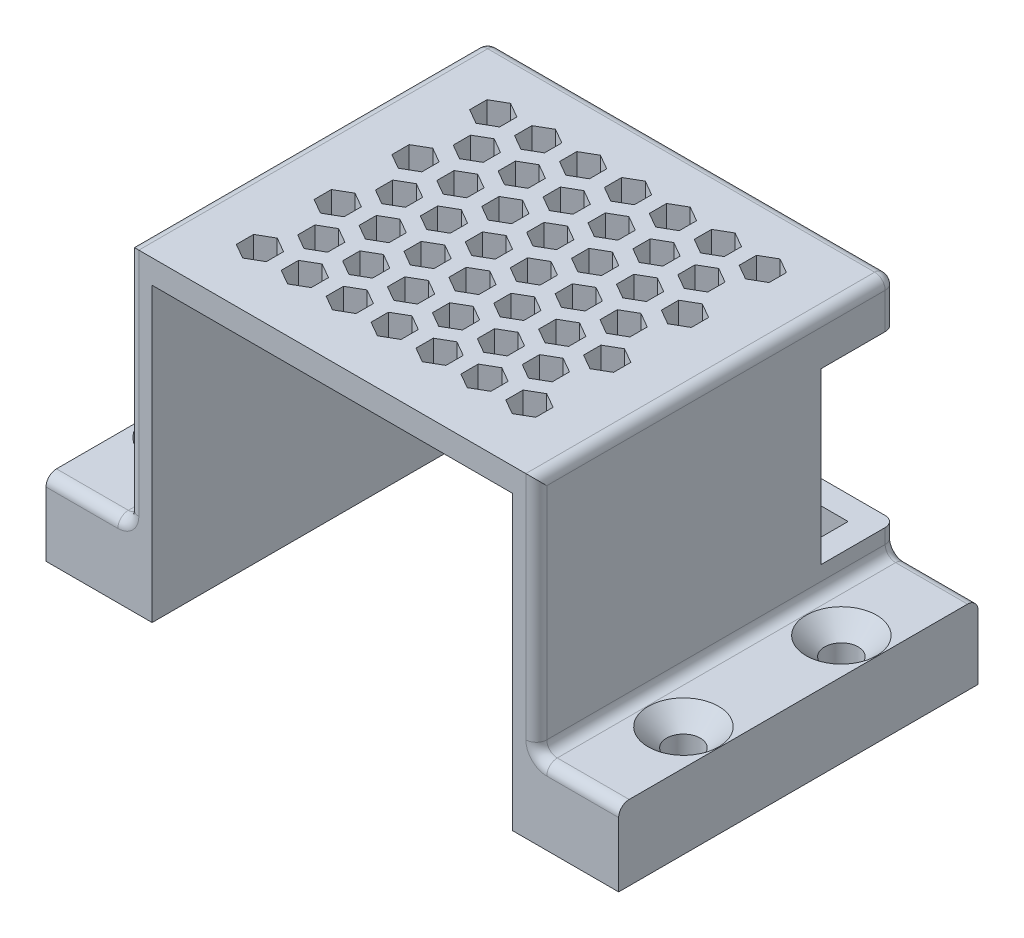
from build123d import *

# Parameters (mm, degrees)
SKETCH1_W                                       = 54.5
SKETCH1_H                                       = 48
BOSS_EXTRUDE1_DEPTH                             = 42.2
SHELL1_T                                        = -3.175
SKETCH2_W                                       = 48
SKETCH2_H                                       = 10
BOSS_EXTRUDE2_DEPTH                             = 11
FILLET1_R                                       = 1.4
FILLET2_R                                       = 1.4
CUT_EXTRUDE1_DEPTH                              = 12
FILLET3_R                                       = 1.4
CSK_FOR_M4_FLAT_HEAD_MACHINE_SCREW1_D           = 4.5
CSK_FOR_M4_FLAT_HEAD_MACHINE_SCREW1_DEPTH       = 10
CSK_FOR_M4_FLAT_HEAD_MACHINE_SCREW1_CSINK_D     = 9.4
CSK_FOR_M4_FLAT_HEAD_MACHINE_SCREW1_CSINK_ANGLE = 90
SKETCH8_W                                       = 21.374873602
SKETCH8_H                                       = 22.656356573
CUT_EXTRUDE2_DEPTH                              = 10


with BuildPart() as part:
    # Sketch1 → Boss-Extrude1 (new body)
    with BuildSketch(Plane(origin=(0, 0, 0), x_dir=(1, 0, 0), z_dir=(0, 1, 0))):
        Rectangle(SKETCH1_W, SKETCH1_H)
    extrude(amount=BOSS_EXTRUDE1_DEPTH)

    # Shell1
    shell1_openings = [part.faces().sort_by_distance(p)[0] for p in [
        (0, 0, 0),
        (0, 21.1, 24),
    ]]
    offset(amount=SHELL1_T, openings=shell1_openings, kind=Kind.INTERSECTION)

    # Sketch2 → Boss-Extrude2 (add)
    with BuildSketch(Plane(origin=(27.25, 0, 0), x_dir=(0, 0, -1), z_dir=(1, 0, 0))):
        with Locations((0, 5)):
            Rectangle(SKETCH2_W, SKETCH2_H)
    boss_extrude2 = extrude(amount=BOSS_EXTRUDE2_DEPTH)

    # Fillet1
    fillet1_edges = [part.edges().sort_by_distance(p)[0] for p in [
        (27.25, 10, 0),
    ]]
    fillet(fillet1_edges, radius=FILLET1_R)

    # Mirror1: Boss-Extrude2 across plane
    add(boss_extrude2.mirror(Plane(origin=(0, 0, 0), x_dir=(0, 0, 1), z_dir=(1, 0, 0))))

    # Fillet2
    fillet2_edges = [part.edges().sort_by_distance(p)[0] for p in [
        (-27.25, 10, 0),
    ]]
    fillet(fillet2_edges, radius=FILLET2_R)

    # Sketch3 → Cut-Extrude1 (cut)
    with BuildSketch(Plane(origin=(0, 42.2, 0), x_dir=(1, 0, 0), z_dir=(0, 1, 0))):
        Polygon((-7, 9.149745962), (-7, 11.459147039), (-9, 12.613847577), (-11, 11.459147039), (-11, 9.149745962), (-9, 7.995045424), align=None)
        Polygon((-13, 9.149745962), (-13, 11.459147039), (-15, 12.613847577), (-17, 11.459147039), (-17, 9.149745962), (-15, 7.995045424), align=None)
        Polygon((-16, 14.345898385), (-16, 16.655299462), (-18, 17.81), (-20, 16.655299462), (-20, 14.345898385), (-18, 13.191197846), align=None)
        Polygon((-10, 14.345898385), (-10, 16.655299462), (-12, 17.81), (-14, 16.655299462), (-14, 14.345898385), (-12, 13.191197846), align=None)
        Polygon((-1, 9.149745962), (-1, 11.459147039), (-3, 12.613847577), (-5, 11.459147039), (-5, 9.149745962), (-3, 7.995045424), align=None)
        Polygon((-4, 14.345898385), (-4, 16.655299462), (-6, 17.81), (-8, 16.655299462), (-8, 14.345898385), (-6, 13.191197846), align=None)
        Polygon((5, 9.149745962), (5, 11.459147039), (3, 12.613847577), (1, 11.459147039), (1, 9.149745962), (3, 7.995045424), align=None)
        Polygon((2, 14.345898385), (2, 16.655299462), (0, 17.81), (-2, 16.655299462), (-2, 14.345898385), (0, 13.191197846), align=None)
        Polygon((11, 9.149745962), (11, 11.459147039), (9, 12.613847577), (7, 11.459147039), (7, 9.149745962), (9, 7.995045424), align=None)
        Polygon((8, 14.345898385), (8, 16.655299462), (6, 17.81), (4, 16.655299462), (4, 14.345898385), (6, 13.191197846), align=None)
        Polygon((17, 9.149745962), (17, 11.459147039), (15, 12.613847577), (13, 11.459147039), (13, 9.149745962), (15, 7.995045424), align=None)
        Polygon((14, 14.345898385), (14, 16.655299462), (12, 17.81), (10, 16.655299462), (10, 14.345898385), (12, 13.191197846), align=None)
        Polygon((20, 14.345898385), (20, 16.655299462), (18, 17.81), (16, 16.655299462), (16, 14.345898385), (18, 13.191197846), align=None)
        Polygon((-7, -1.240254038), (-7, 1.069147039), (-9, 2.223847577), (-11, 1.069147039), (-11, -1.240254038), (-9, -2.394954576), align=None)
        Polygon((-10, 3.955898385), (-10, 6.265299462), (-12, 7.42), (-14, 6.265299462), (-14, 3.955898385), (-12, 2.801197846), align=None)
        Polygon((-1, -1.240254038), (-1, 1.069147039), (-3, 2.223847577), (-5, 1.069147039), (-5, -1.240254038), (-3, -2.394954576), align=None)
        Polygon((-4, 3.955898385), (-4, 6.265299462), (-6, 7.42), (-8, 6.265299462), (-8, 3.955898385), (-6, 2.801197846), align=None)
        Polygon((5, -1.240254038), (5, 1.069147039), (3, 2.223847577), (1, 1.069147039), (1, -1.240254038), (3, -2.394954576), align=None)
        Polygon((2, 3.955898385), (2, 6.265299462), (0, 7.42), (-2, 6.265299462), (-2, 3.955898385), (0, 2.801197846), align=None)
        Polygon((11, -1.240254038), (11, 1.069147039), (9, 2.223847577), (7, 1.069147039), (7, -1.240254038), (9, -2.394954576), align=None)
        Polygon((8, 3.955898385), (8, 6.265299462), (6, 7.42), (4, 6.265299462), (4, 3.955898385), (6, 2.801197846), align=None)
        Polygon((17, -1.240254038), (17, 1.069147039), (15, 2.223847577), (13, 1.069147039), (13, -1.240254038), (15, -2.394954576), align=None)
        Polygon((14, 3.955898385), (14, 6.265299462), (12, 7.42), (10, 6.265299462), (10, 3.955898385), (12, 2.801197846), align=None)
        Polygon((20, 3.955898385), (20, 6.265299462), (18, 7.42), (16, 6.265299462), (16, 3.955898385), (18, 2.801197846), align=None)
        Polygon((-7, -11.630254038), (-7, -9.320852961), (-9, -8.166152423), (-11, -9.320852961), (-11, -11.630254038), (-9, -12.784954576), align=None)
        Polygon((-10, -6.434101615), (-10, -4.124700538), (-12, -2.97), (-14, -4.124700538), (-14, -6.434101615), (-12, -7.588802154), align=None)
        Polygon((-1, -11.630254038), (-1, -9.320852961), (-3, -8.166152423), (-5, -9.320852961), (-5, -11.630254038), (-3, -12.784954576), align=None)
        Polygon((-4, -6.434101615), (-4, -4.124700538), (-6, -2.97), (-8, -4.124700538), (-8, -6.434101615), (-6, -7.588802154), align=None)
        Polygon((5, -11.630254038), (5, -9.320852961), (3, -8.166152423), (1, -9.320852961), (1, -11.630254038), (3, -12.784954576), align=None)
        Polygon((2, -6.434101615), (2, -4.124700538), (0, -2.97), (-2, -4.124700538), (-2, -6.434101615), (0, -7.588802154), align=None)
        Polygon((11, -11.630254038), (11, -9.320852961), (9, -8.166152423), (7, -9.320852961), (7, -11.630254038), (9, -12.784954576), align=None)
        Polygon((8, -6.434101615), (8, -4.124700538), (6, -2.97), (4, -4.124700538), (4, -6.434101615), (6, -7.588802154), align=None)
        Polygon((17, -11.630254038), (17, -9.320852961), (15, -8.166152423), (13, -9.320852961), (13, -11.630254038), (15, -12.784954576), align=None)
        Polygon((14, -6.434101615), (14, -4.124700538), (12, -2.97), (10, -4.124700538), (10, -6.434101615), (12, -7.588802154), align=None)
        Polygon((20, -6.434101615), (20, -4.124700538), (18, -2.97), (16, -4.124700538), (16, -6.434101615), (18, -7.588802154), align=None)
        Polygon((-10, -16.824101615), (-10, -14.514700538), (-12, -13.36), (-14, -14.514700538), (-14, -16.824101615), (-12, -17.978802154), align=None)
        Polygon((-4, -16.824101615), (-4, -14.514700538), (-6, -13.36), (-8, -14.514700538), (-8, -16.824101615), (-6, -17.978802154), align=None)
        Polygon((2, -16.824101615), (2, -14.514700538), (0, -13.36), (-2, -14.514700538), (-2, -16.824101615), (0, -17.978802154), align=None)
        Polygon((8, -16.824101615), (8, -14.514700538), (6, -13.36), (4, -14.514700538), (4, -16.824101615), (6, -17.978802154), align=None)
        Polygon((14, -16.824101615), (14, -14.514700538), (12, -13.36), (10, -14.514700538), (10, -16.824101615), (12, -17.978802154), align=None)
        Polygon((20, -16.824101615), (20, -14.514700538), (18, -13.36), (16, -14.514700538), (16, -16.824101615), (18, -17.978802154), align=None)
        Polygon((-13, -1.240254038), (-13, 1.069147039), (-15, 2.223847577), (-17, 1.069147039), (-17, -1.240254038), (-15, -2.394954576), align=None)
        Polygon((-16, 3.955898385), (-16, 6.265299462), (-18, 7.42), (-20, 6.265299462), (-20, 3.955898385), (-18, 2.801197846), align=None)
        Polygon((-13, -11.630254038), (-13, -9.320852961), (-15, -8.166152423), (-17, -9.320852961), (-17, -11.630254038), (-15, -12.784954576), align=None)
        Polygon((-16, -6.434101615), (-16, -4.124700538), (-18, -2.97), (-20, -4.124700538), (-20, -6.434101615), (-18, -7.588802154), align=None)
        Polygon((-16, -16.824101615), (-16, -14.514700538), (-18, -13.36), (-20, -14.514700538), (-20, -16.824101615), (-18, -17.978802154), align=None)
    extrude(amount=-CUT_EXTRUDE1_DEPTH, mode=Mode.SUBTRACT)

    # Fillet3
    fillet3_edges = [part.edges().sort_by_distance(p)[0] for p in [
        (27.25, 42.2, 0),
        (0, 42.2, -24),
        (33.45, 10, 24),
        (33.45, 10, -24),
        (27.660050506, 10.410050506, 24),
        (27.660050506, 10.410050506, -24),
        (-33.45, 10, 24),
        (-33.45, 10, -24),
        (-27.25, 42.2, 0),
        (-27.660050506, 10.410050506, 24),
        (-27.660050506, 10.410050506, -24),
        (-27.25, 26.8, -24),
        (27.25, 26.8, -24),
        (27.25, 26.8, 24),
        (-27.25, 26.8, 24),
    ]]
    fillet(fillet3_edges, radius=FILLET3_R)

    # CSK for M4 Flat Head Machine Screw1
    with Locations(Plane(origin=(0, 10, 0), x_dir=(1, 0, 0), z_dir=(0, 1, 0))):
        with Locations((-33.45, -10.55), (-33.45, 10.55)):
            csk_for_m4_flat_head_machine_screw1 = CounterSinkHole(CSK_FOR_M4_FLAT_HEAD_MACHINE_SCREW1_D / 2, CSK_FOR_M4_FLAT_HEAD_MACHINE_SCREW1_CSINK_D / 2, depth=CSK_FOR_M4_FLAT_HEAD_MACHINE_SCREW1_DEPTH, counter_sink_angle=CSK_FOR_M4_FLAT_HEAD_MACHINE_SCREW1_CSINK_ANGLE)

    # Mirror2: CSK for M4 Flat Head Machine Screw1 across plane
    add(csk_for_m4_flat_head_machine_screw1.mirror(Plane(origin=(0, 0, 0), x_dir=(0, 0, 1), z_dir=(1, 0, 0))), mode=Mode.SUBTRACT)

    # Sketch8 → Cut-Extrude2 (cut)
    with BuildSketch(Plane(origin=(0, 0, -24), x_dir=(-1, 0, 0), z_dir=(0, 0, -1))):
        with Locations((-25.85, 24.683228981)):
            Rectangle(SKETCH8_W, SKETCH8_H)
    cut_extrude2 = extrude(amount=-CUT_EXTRUDE2_DEPTH, mode=Mode.SUBTRACT)

    # Mirror3: Cut-Extrude2 across plane
    add(cut_extrude2.mirror(Plane(origin=(0, 0, 0), x_dir=(0, 0, 1), z_dir=(1, 0, 0))), mode=Mode.SUBTRACT)


solid = part.part
